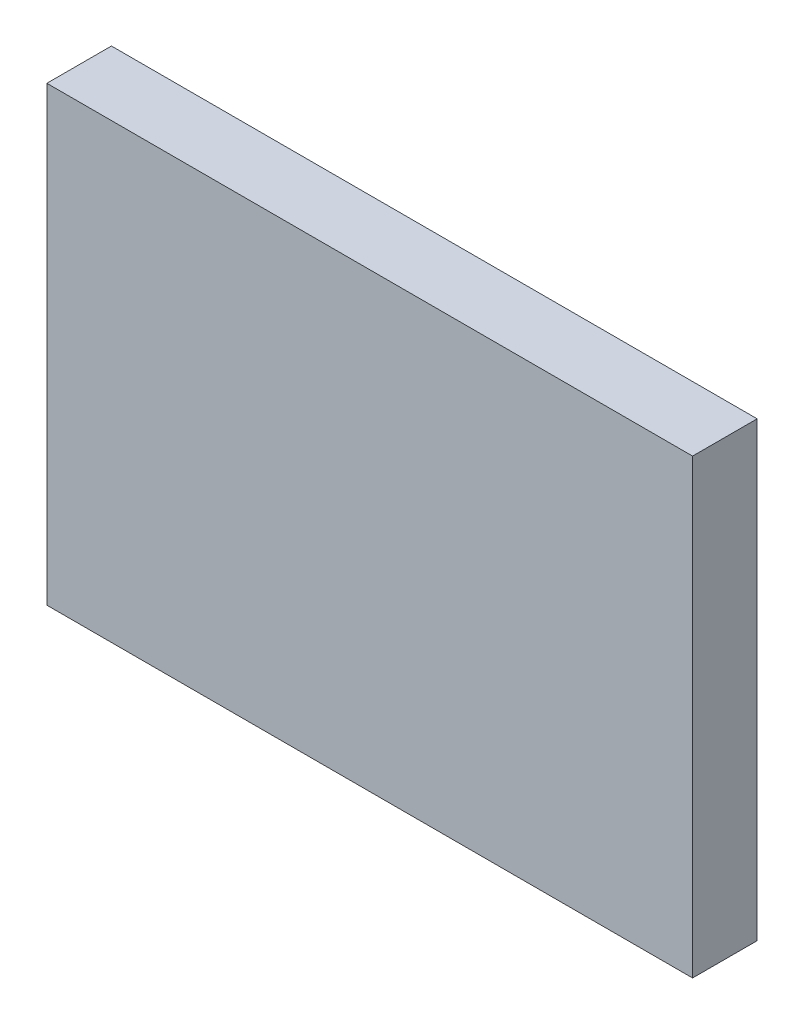
from build123d import *

# Parameters (mm, degrees)
SKETCH1_W           = 100
SKETCH1_H           = 70
BOSS_EXTRUDE1_DEPTH = 10


with BuildPart() as part:
    # Sketch1 → Boss-Extrude1 (new body)
    with BuildSketch(Plane.XY):
        with Locations((50, 35)):
            Rectangle(SKETCH1_W, SKETCH1_H)
    extrude(amount=BOSS_EXTRUDE1_DEPTH)


solid = part.part
